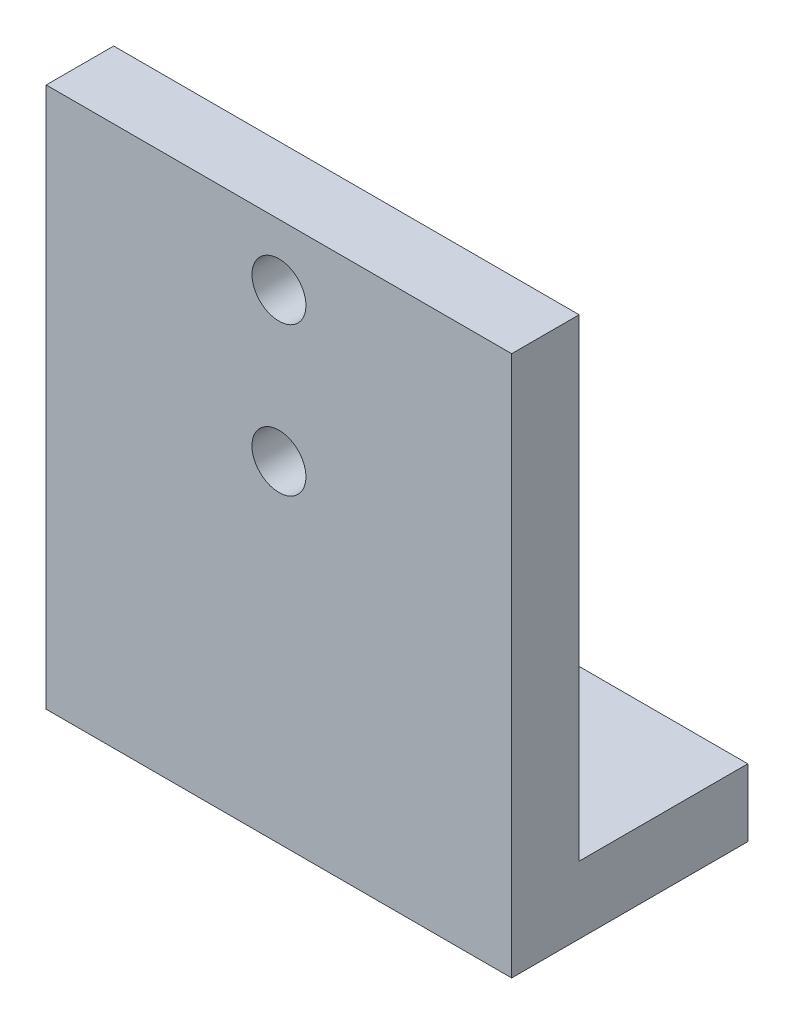
from build123d import *

# Parameters (mm, degrees)
BOSS_EXTRUDE1_DEPTH = 69
SKETCH2_R           = 4
CUT_EXTRUDE1_DEPTH  = 11
SKETCH3_R           = 3
CUT_EXTRUDE2_DEPTH  = 10


with BuildPart() as part:
    # Sketch1 → Boss-Extrude1 (new body)
    with BuildSketch(Plane(origin=(0, 0, 0), x_dir=(0, 0, -1), z_dir=(1, 0, 0))):
        Polygon((0, 80.15), (0, 0), (35, 0), (35, 10), (10, 10), (10, 80.15), align=None)
    extrude(amount=BOSS_EXTRUDE1_DEPTH)

    # Sketch2 → Cut-Extrude1 (cut, through all)
    with BuildSketch(Plane(origin=(0, 0, -10), x_dir=(-1, 0, 0), z_dir=(0, 0, -1))):
        with Locations((-34.5, 71.08)):
            Circle(SKETCH2_R)
        with Locations((-34.5, 49.08)):
            Circle(SKETCH2_R)
    extrude(amount=-CUT_EXTRUDE1_DEPTH, mode=Mode.SUBTRACT)

    # Sketch3 → Cut-Extrude2 (cut)
    with BuildSketch(Plane(origin=(0, 10, 0), x_dir=(1, 0, 0), z_dir=(0, 1, 0))):
        with Locations((17, 22.5)):
            Circle(SKETCH3_R)
        with Locations((52, 22.5)):
            Circle(SKETCH3_R)
    extrude(amount=-CUT_EXTRUDE2_DEPTH, mode=Mode.SUBTRACT)


solid = part.part
